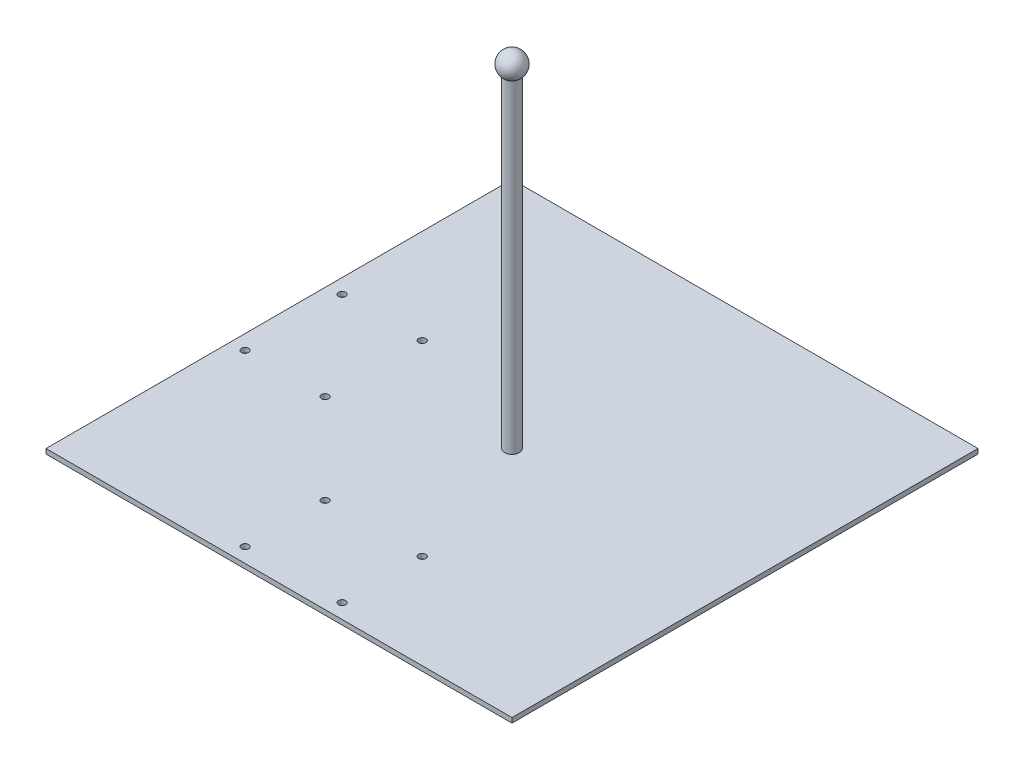
from build123d import *

# Parameters (mm, degrees)
SKETCH1_W                        = 609.6
SKETCH1_H                        = 609.6
BOSS_EXTRUDE1_DEPTH              = 6.35
F_3_8_0_375_DIAMETER_HOLE1_D     = 9.525
F_3_8_0_375_DIAMETER_HOLE1_DEPTH = 11.684
F_3_8_0_375_DIAMETER_HOLE1_TIP   = 2.861598698
SKETCH4_R                        = 9.525
BOSS_EXTRUDE2_DEPTH              = 422.91


with BuildPart() as part:
    # Sketch1 → Boss-Extrude1 (new body)
    with BuildSketch(Plane(origin=(0, 0, 0), x_dir=(1, 0, 0), z_dir=(0, 1, 0))):
        Rectangle(SKETCH1_W, SKETCH1_H)
    extrude(amount=BOSS_EXTRUDE1_DEPTH)

    # 3/8 (0.375) Diameter Hole1
    with Locations(Plane(origin=(0, 6.35, 0), x_dir=(1, 0, 0), z_dir=(0, 1, 0))):
        with Locations((-63.5, -285.75), (63.5, -285.75), (-285.75, 63.5), (-285.75, -63.5), (-63.5, -180.975), (63.5, -180.975), (-180.975, -63.5), (-180.975, 63.5)):
            Hole(F_3_8_0_375_DIAMETER_HOLE1_D / 2, depth=F_3_8_0_375_DIAMETER_HOLE1_DEPTH)
            with Locations((0, 0, -(F_3_8_0_375_DIAMETER_HOLE1_DEPTH + F_3_8_0_375_DIAMETER_HOLE1_TIP / 2))):  # 118° drill point
                Cone(0, F_3_8_0_375_DIAMETER_HOLE1_D / 2, F_3_8_0_375_DIAMETER_HOLE1_TIP, mode=Mode.SUBTRACT)

    # Sketch4 → Boss-Extrude2 (add)
    with BuildSketch(Plane(origin=(0, 6.35, 0), x_dir=(1, 0, 0), z_dir=(0, 1, 0))):
        Circle(SKETCH4_R)
    extrude(amount=BOSS_EXTRUDE2_DEPTH)

    # Sketch5 → Revolve3 (revolve)
    with BuildSketch(Plane.XY):
        with BuildLine():
            Line((0, 457.835), (0, 426.085))
            ThreePointArc((0, 426.085), (-15.875, 441.96), (0, 457.835))
        make_face()
    revolve(axis=Axis((0, 599.823656089, 0), (0, -1, 0)))


solid = part.part
